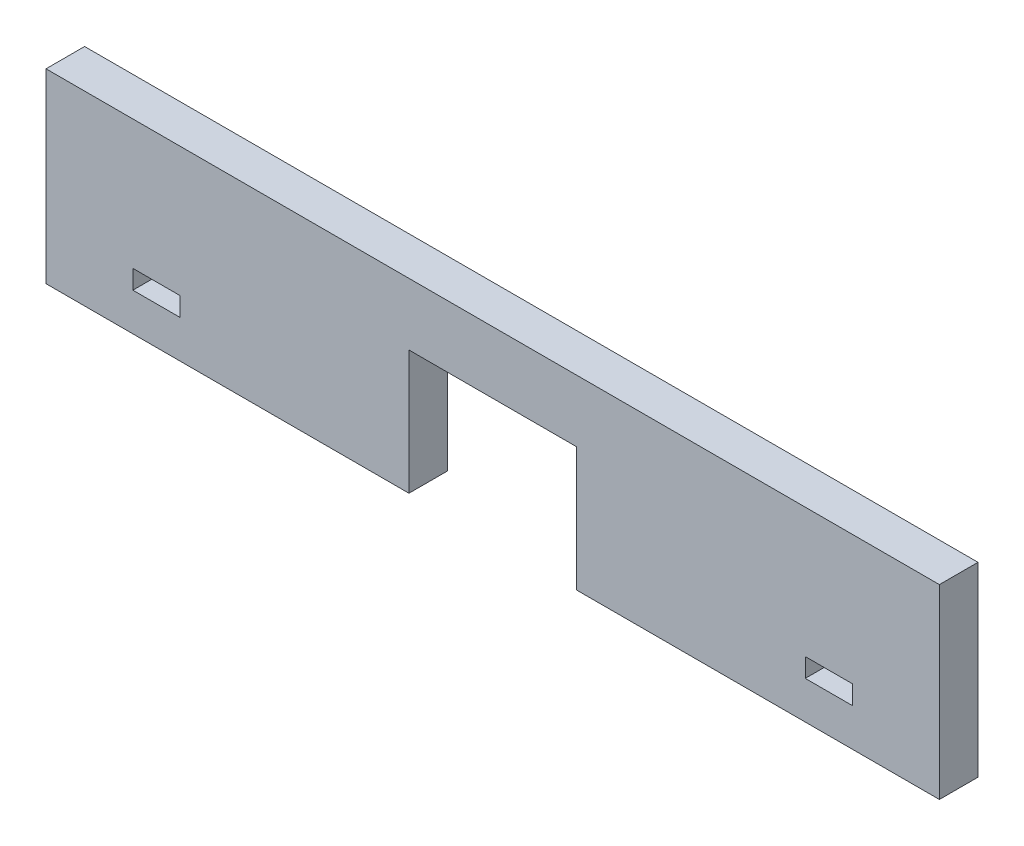
from build123d import *

# Parameters (mm, degrees)
SKETCH1_W           = 3.81
SKETCH1_H           = 1.524
BOSS_EXTRUDE1_DEPTH = 3.1115


with BuildPart() as part:
    # Sketch1 → Boss-Extrude1 (new body)
    with BuildSketch(Plane.XY):
        Polygon((-36.017419718, -7.591435707), (-6.767419718, -7.591435707), (-6.767419718, 2.408564293), (6.732580282, 2.408564293), (6.732580282, -7.591435707), (35.982580282, -7.591435707), (35.982580282, -5.091435707), (35.982580282, 4.908564293), (35.982580282, 7.408564293), (-36.017419718, 7.408564293), (-36.017419718, 4.908564293), (-36.017419718, -5.091435707), align=None)
        with Locations((27.077580282, -3.781435707)):
            Rectangle(SKETCH1_W, SKETCH1_H, mode=Mode.SUBTRACT)
        with Locations((-27.112419718, -3.781435707)):
            Rectangle(SKETCH1_W, SKETCH1_H, mode=Mode.SUBTRACT)
    extrude(amount=BOSS_EXTRUDE1_DEPTH)


solid = part.part
